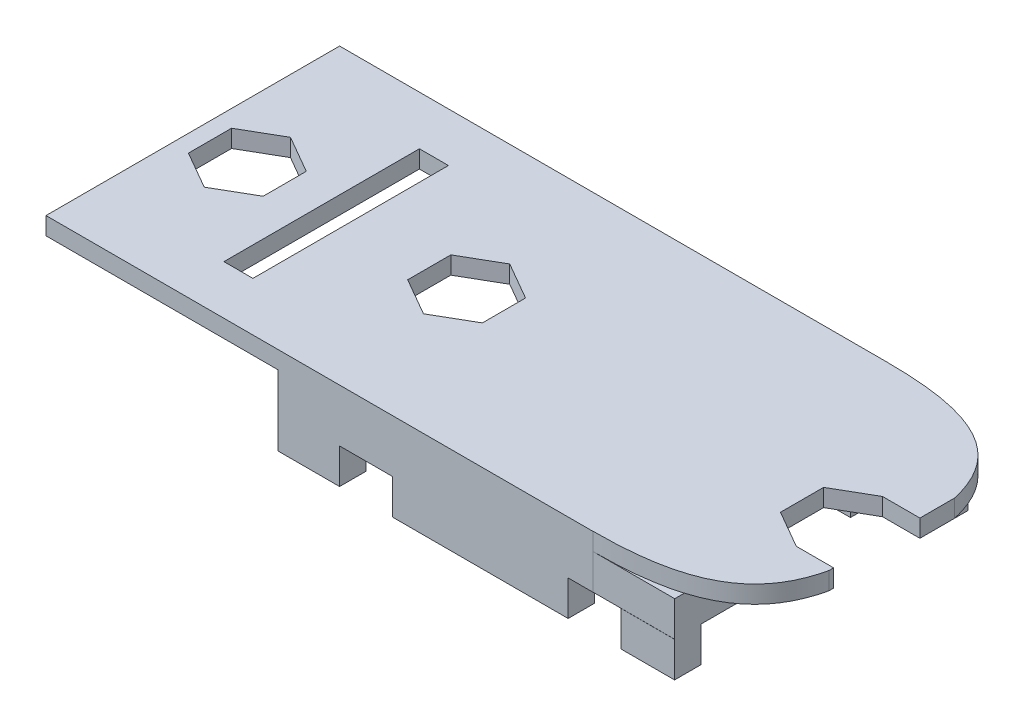
from build123d import *

# Parameters (mm, degrees)
SKETCH1_W              = 22.5552
SKETCH1_H              = 12.7
BOSS_EXTRUDE1_DEPTH    = 1
SKETCH2_W              = 5
SKETCH2_H              = 7.3
CUT_EXTRUDE1_DEPTH     = 1
SKETCH3_W              = 5
SKETCH3_H              = 5
CUT_EXTRUDE2_DEPTH     = 1
SKETCH4_W              = 22.0552
SKETCH4_H              = 0.5
SKETCH4_W_2            = 0.5
SKETCH4_H_2            = 1.5
SKETCH4_H_3            = 2
BOSS_EXTRUDE2_DEPTH    = 1
SKETCH5_W              = 39.7552
SKETCH5_H              = 16.7
BOSS_EXTRUDE3_DEPTH    = 1
CUT_EXTRUDE3_DEPTH     = 1
CUT_EXTRUDE4_DEPTH     = 1
CUT_EXTRUDE5_START     = -4
CUT_EXTRUDE5_DEPTH     = 5
SKETCH10_W             = 22.5552
SKETCH10_H             = 2
BOSS_EXTRUDE4_DEPTH    = 2
SKETCH11_W             = 8.919893548
SKETCH11_H             = 0.730490532
CUT_EXTRUDE6_DEPTH     = 3
SKETCH12_W             = 22.5552
SKETCH12_H             = 1.5
BOSS_EXTRUDE5_DEPTH    = 2
SKETCH13_W             = 3
SKETCH13_H             = 1.5
CUT_EXTRUDE7_DEPTH     = 2
SKETCH14_W             = 2.125
SKETCH14_H             = 1.226869322
CUT_EXTRUDE8_DEPTH     = 1
SKETCH15_W             = 1.65
SKETCH15_H             = 11.12
ADAPTER_PCB_HOLE_DEPTH = 1
CUT_EXTRUDE10_DEPTH    = 1


with BuildPart() as part:
    # Sketch1 → Boss-Extrude1 (new body)
    with BuildSketch(Plane(origin=(0, 0, 0), x_dir=(1, 0, 0), z_dir=(0, 1, 0))):
        with Locations((-28.763088774, 14.606547542)):
            Rectangle(SKETCH1_W, SKETCH1_H)
    extrude(amount=BOSS_EXTRUDE1_DEPTH)

    # Sketch2 → Cut-Extrude1 (cut)
    with BuildSketch(Plane(origin=(0, 1, 0), x_dir=(1, 0, 0), z_dir=(0, 1, 0))):
        with Locations((-37.540688774, 14.606547542)):
            Rectangle(SKETCH2_W, SKETCH2_H)
    extrude(amount=-CUT_EXTRUDE1_DEPTH, mode=Mode.SUBTRACT)

    # Sketch3 → Cut-Extrude2 (cut)
    with BuildSketch(Plane(origin=(0, 1, 0), x_dir=(1, 0, 0), z_dir=(0, 1, 0))):
        with Locations((-19.985488774, 13.756547542)):
            Rectangle(SKETCH3_W, SKETCH3_H)
    extrude(amount=-CUT_EXTRUDE2_DEPTH, mode=Mode.SUBTRACT)

    # Sketch4 → Boss-Extrude2 (add)
    with BuildSketch(Plane.XZ):
        with Locations((-29.013088774, -8.506547542)):
            Rectangle(SKETCH4_W, SKETCH4_H)
        with Locations((-17.735488774, -8.506547542)):
            Rectangle(SKETCH4_W_2, SKETCH4_H)
        with Locations((-17.735488774, -9.506547542)):
            Rectangle(SKETCH4_W_2, SKETCH4_H_2)
        with Locations((-29.013088774, -20.706547542)):
            Rectangle(SKETCH4_W, SKETCH4_H)
        with Locations((-17.735488774, -19.456547542)):
            Rectangle(SKETCH4_W_2, SKETCH4_H_3)
        with Locations((-17.735488774, -20.706547542)):
            Rectangle(SKETCH4_W_2, SKETCH4_H)
    extrude(amount=BOSS_EXTRUDE2_DEPTH)

    # Sketch5 → Boss-Extrude3 (add)
    with BuildSketch(Plane(origin=(0, 1, 0), x_dir=(1, 0, 0), z_dir=(0, 1, 0))):
        with Locations((-33.363088774, 14.606547542)):
            Rectangle(SKETCH5_W, SKETCH5_H)
    extrude(amount=BOSS_EXTRUDE3_DEPTH)

    # Sketch6 → Cut-Extrude3 (cut)
    with BuildSketch(Plane(origin=(0, 2, 0), x_dir=(1, 0, 0), z_dir=(0, 1, 0))):
        Polygon((-39.790688774, 13.37967822), (-37.665688774, 12.152808898), (-35.540688774, 13.37967822), (-35.540688774, 15.833416864), (-37.665688774, 17.060286186), (-39.790688774, 15.833416864), align=None)
    extrude(amount=-CUT_EXTRUDE3_DEPTH, mode=Mode.SUBTRACT)

    # Sketch7 → Cut-Extrude4 (cut)
    with BuildSketch(Plane(origin=(0, 1, 0), x_dir=(-1, 0, 0), z_dir=(0, -1, 0))):
        Polygon((17.735488774, 14.983416864), (15.610488774, 16.210286186), (13.485488774, 14.983416864), (13.485488774, 12.52967822), (15.610488774, 11.302808898), (17.735488774, 12.52967822), align=None)
    extrude(amount=-CUT_EXTRUDE4_DEPTH, mode=Mode.SUBTRACT)

    # Sketch8 → Cut-Extrude5 (cut)
    with BuildSketch(Plane(origin=(0, 2, 0), x_dir=(1, 0, 0), z_dir=(0, 1, 0)).offset(CUT_EXTRUDE5_START)):
        with BuildLine():
            Line((-13.485488774, 22.956547542), (-22.127760886, 22.956547542))
            add(Edge.make_bspline(
                [(-22.127760886, 22.956547542), (-17.367981555, 22.956547542), (-14.30272025, 21.87197064), (-13.485488774, 18.176213027)],
                knots=[0, 0, 0, 0, 1, 1, 1, 1], degree=3))
            Line((-13.485488774, 18.176213027), (-13.485488774, 22.956547542))
        make_face()
    cut_extrude5 = extrude(amount=CUT_EXTRUDE5_DEPTH, mode=Mode.SUBTRACT)

    # Mirror2: Cut-Extrude5 across plane
    add(cut_extrude5.mirror(Plane.XY.offset(-14.61)), mode=Mode.SUBTRACT)

    # Sketch10 → Boss-Extrude4 (add)
    with BuildSketch(Plane(origin=(0, 1, 0), x_dir=(-1, 0, 0), z_dir=(0, -1, 0))):
        with Locations((28.763088774, 7.256547542)):
            Rectangle(SKETCH10_W, SKETCH10_H)
        with Locations((28.763088774, 21.956547542)):
            Rectangle(SKETCH10_W, SKETCH10_H)
    extrude(amount=BOSS_EXTRUDE4_DEPTH)

    # Sketch11 → Cut-Extrude6 (cut)
    with BuildSketch(Plane(origin=(0, 2, 0), x_dir=(1, 0, 0), z_dir=(0, 1, 0))):
        with Locations((-17.667814112, 5.898207192)):
            Rectangle(SKETCH11_W, SKETCH11_H)
    extrude(amount=-CUT_EXTRUDE6_DEPTH, mode=Mode.SUBTRACT)

    # Sketch12 → Boss-Extrude5 (add)
    with BuildSketch(Plane(origin=(0, -1, 0), x_dir=(-1, 0, 0), z_dir=(0, -1, 0))):
        with Locations((28.763088774, 7.006547542)):
            Rectangle(SKETCH12_W, SKETCH12_H)
        with Locations((28.763088774, 22.206547542)):
            Rectangle(SKETCH12_W, SKETCH12_H)
    extrude(amount=BOSS_EXTRUDE5_DEPTH)

    # Sketch13 → Cut-Extrude7 (cut)
    with BuildSketch(Plane(origin=(0, -3, 0), x_dir=(-1, 0, 0), z_dir=(0, -1, 0))):
        with Locations((35.040688774, 7.006547542)):
            Rectangle(SKETCH13_W, SKETCH13_H)
        with Locations((35.040688774, 22.206547542)):
            Rectangle(SKETCH13_W, SKETCH13_H)
        with Locations((22.040688774, 7.006547542)):
            Rectangle(SKETCH13_W, SKETCH13_H)
        with Locations((22.040688774, 22.206547542)):
            Rectangle(SKETCH13_W, SKETCH13_H)
    extrude(amount=-CUT_EXTRUDE7_DEPTH, mode=Mode.SUBTRACT)

    # Sketch14 → Cut-Extrude8 (cut)
    with BuildSketch(Plane(origin=(0, 2, 0), x_dir=(1, 0, 0), z_dir=(0, 1, 0))):
        with Locations((-14.547988774, 15.596851525)):
            Rectangle(SKETCH14_W, SKETCH14_H)
        with Locations((-14.547988774, 11.916243559)):
            Rectangle(SKETCH14_W, SKETCH14_H)
    extrude(amount=-CUT_EXTRUDE8_DEPTH, mode=Mode.SUBTRACT)

    # Sketch15 → adapter_PCB_hole (cut)
    with BuildSketch(Plane(origin=(0, 1, 0), x_dir=(-1, 0, 0), z_dir=(0, -1, 0))):
        with Locations((45.085688774, 14.606547542)):
            Rectangle(SKETCH15_W, SKETCH15_H)
    extrude(amount=-ADAPTER_PCB_HOLE_DEPTH, mode=Mode.SUBTRACT)

    # Sketch22 → Cut-Extrude10 (cut)
    with BuildSketch(Plane(origin=(0, 1, 0), x_dir=(-1, 0, 0), z_dir=(0, -1, 0))):
        Polygon((52.265688774, 15.836869322), (50.140688774, 17.063738644), (48.015688774, 15.836869322), (48.015688774, 13.383130678), (50.140688774, 12.156261356), (52.265688774, 13.383130678), align=None)
    extrude(amount=-CUT_EXTRUDE10_DEPTH, mode=Mode.SUBTRACT)


solid = part.part
